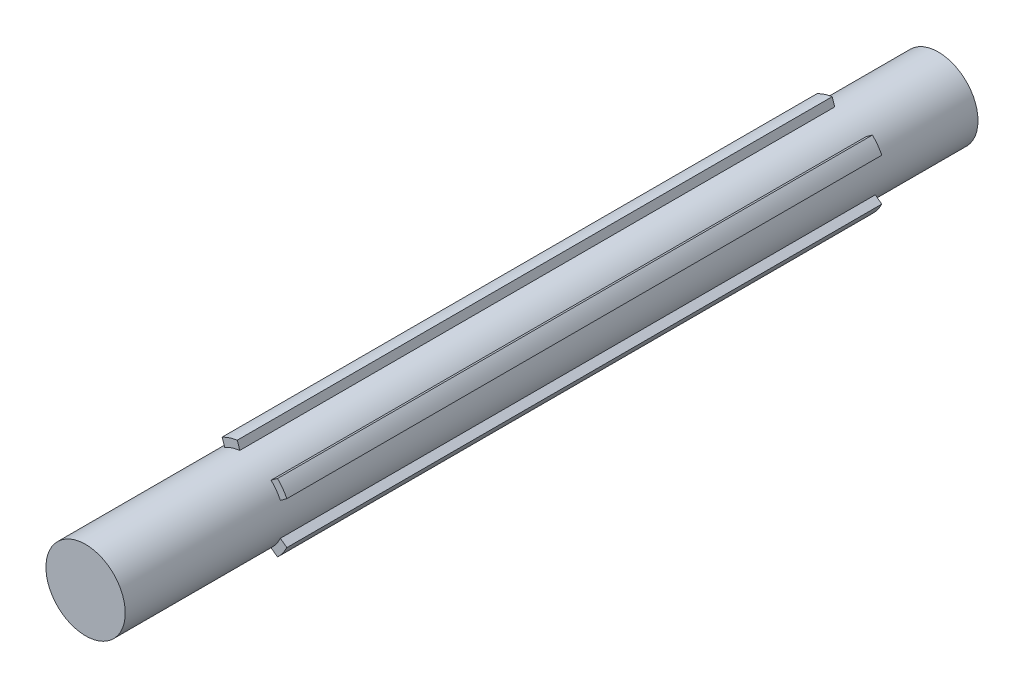
from build123d import *

# Parameters (mm, degrees)
IZIM1_R                     = 10
Y_KSEKLIK_EKSTR_ZYON1_DEPTH = 215
Y_KSEKLIK_EKSTR_ZYON2_DEPTH = 150


with BuildPart() as part:
    # Çizim1 → Yükseklik-Ekstrüzyon1 (new body)
    with BuildSketch(Plane.XY):
        Circle(IZIM1_R)
    extrude(amount=-Y_KSEKLIK_EKSTR_ZYON1_DEPTH)

    # Çizim2 → Yükseklik-Ekstrüzyon2 (add)
    with BuildSketch(Plane.XY.offset(-40)):
        with BuildLine():
            ThreePointArc((-9.797958971, -2), (-10, 0), (-9.797958971, 2))
            Line((-9.797958971, 2), (-11.832159566, 2))
            ThreePointArc((-11.832159566, 2), (-12, 0), (-11.832159566, -2))
            Line((-11.832159566, -2), (-9.797958971, -2))
        make_face()
        with BuildLine():
            Line((-1.1256228, 9.936446715), (-1.754225354, 11.871086446))
            ThreePointArc((-1.754225354, 11.871086446), (-3.708203932, 11.412678196), (-5.558451419, 10.635018469))
            Line((-5.558451419, 10.635018469), (-4.929848865, 8.700378737))
            ThreePointArc((-4.929848865, 8.700378737), (-3.090169944, 9.510565163), (-1.1256228, 9.936446715))
        make_face()
        with BuildLine():
            Line((8.396847665, 8.572802885), (6.751144813, 7.377129775))
            ThreePointArc((6.751144813, 7.377129775), (8.090169944, 5.877852523), (9.102285822, 4.141061797))
            Line((9.102285822, 4.141061797), (10.747988674, 5.336734907))
            ThreePointArc((10.747988674, 5.336734907), (9.708203932, 7.053423028), (8.396847665, 8.572802885))
        make_face()
        with BuildLine():
            Line((10.747988674, -5.336734907), (9.102285822, -4.141061797))
            ThreePointArc((9.102285822, -4.141061797), (8.090169944, -5.877852523), (6.751144813, -7.377129775))
            Line((6.751144813, -7.377129775), (8.396847665, -8.572802885))
            ThreePointArc((8.396847665, -8.572802885), (9.708203932, -7.053423028), (10.747988674, -5.336734907))
        make_face()
        with BuildLine():
            ThreePointArc((-1.1256228, -9.936446715), (-3.090169944, -9.510565163), (-4.929848865, -8.700378737))
            Line((-4.929848865, -8.700378737), (-5.558451419, -10.635018469))
            ThreePointArc((-5.558451419, -10.635018469), (-3.708203932, -11.412678196), (-1.754225354, -11.871086446))
            Line((-1.754225354, -11.871086446), (-1.1256228, -9.936446715))
        make_face()
    extrude(amount=-Y_KSEKLIK_EKSTR_ZYON2_DEPTH)


solid = part.part
